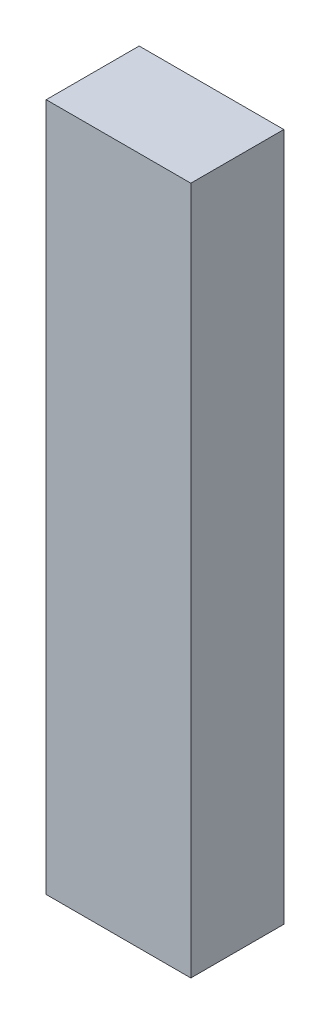
from build123d import *

# Parameters (mm, degrees)
SKETCH1_W               = 70
SKETCH1_H               = 45
SHAPE_DEPTH             = 1000
SKETCH6_W               = 70
SKETCH6_H               = 666.851692929
CUT_EXTRUDE2_DEPTH      = 1
CUT_EXTRUDE2_DEPTH_BACK = 46


with BuildPart() as part:
    # Sketch1 → Shape (new body)
    with BuildSketch(Plane(origin=(0, 0, 0), x_dir=(1, 0, 0), z_dir=(0, 1, 0))):
        Rectangle(SKETCH1_W, SKETCH1_H)
    extrude(amount=SHAPE_DEPTH)

    # Sketch6 → Cut-Extrude2 (cut, two sides)
    with BuildSketch(Plane.XY.offset(22.5)) as cut_extrude2_sk:
        with Locations((0, 333.425846465)):
            Rectangle(SKETCH6_W, SKETCH6_H)
    extrude(amount=CUT_EXTRUDE2_DEPTH, mode=Mode.SUBTRACT)
    extrude(cut_extrude2_sk.sketch, amount=-CUT_EXTRUDE2_DEPTH_BACK, mode=Mode.SUBTRACT)


solid = part.part
